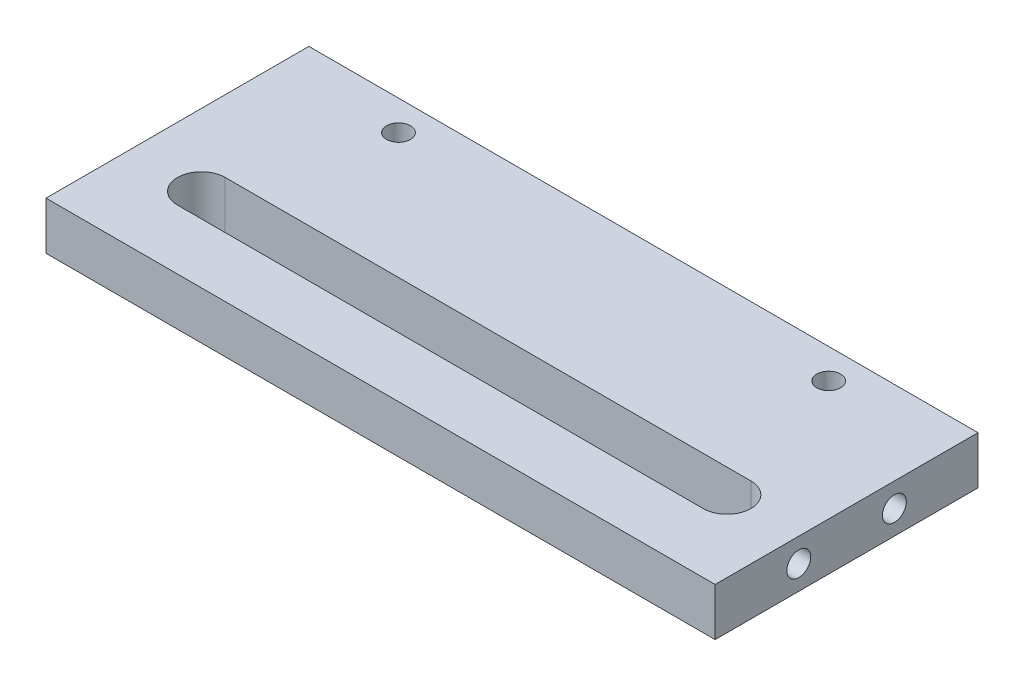
from build123d import *

# Parameters (mm, degrees)
CROQUIS1_W              = 280
CROQUIS1_H              = 110
SALIENTE_EXTRUIR1_DEPTH = 20
CORTAR_EXTRUIR2_DEPTH   = 20
CROQUIS4_R              = 5
CORTAR_EXTRUIR4_DEPTH   = 20
CROQUIS5_R              = 5
CORTAR_EXTRUIR5_DEPTH   = 18
CROQUIS6_R              = 5
CORTAR_EXTRUIR6_DEPTH   = 18


with BuildPart() as part:
    # Croquis1 → Saliente-Extruir1 (new body)
    with BuildSketch(Plane(origin=(0, 0, 0), x_dir=(1, 0, 0), z_dir=(0, 1, 0))):
        with Locations((14.294294294, 1.756756757)):
            Rectangle(CROQUIS1_W, CROQUIS1_H)
    extrude(amount=SALIENTE_EXTRUIR1_DEPTH)

    # Croquis2 → Cortar-Extruir2 (cut)
    with BuildSketch(Plane(origin=(0, 0, 0), x_dir=(1, 0, 0), z_dir=(0, 1, 0))):
        with BuildLine():
            Line((-95.705705706, -8.243243243), (124.294294294, -8.243243243))
            ThreePointArc((124.294294294, -8.243243243), (134.294294294, -18.243243243), (124.294294294, -28.243243243))
            Line((124.294294294, -28.243243243), (-95.705705706, -28.243243243))
            ThreePointArc((-95.705705706, -28.243243243), (-105.705705706, -18.243243243), (-95.705705706, -8.243243243))
        make_face()
    extrude(amount=CORTAR_EXTRUIR2_DEPTH, mode=Mode.SUBTRACT)

    # Croquis4 → Cortar-Extruir4 (cut)
    with BuildSketch(Plane(origin=(0, 0, 0), x_dir=(1, 0, 0), z_dir=(0, 1, 0))):
        with Locations((104.294294294, 44.256756757)):
            Circle(CROQUIS4_R)
        with Locations((-75.705705706, 44.256756757)):
            Circle(CROQUIS4_R)
    extrude(amount=CORTAR_EXTRUIR4_DEPTH, mode=Mode.SUBTRACT)

    # Croquis5 → Cortar-Extruir5 (cut)
    with BuildSketch(Plane.ZY.offset(125.705705706)):
        with Locations((18.243243243, 10)):
            Circle(CROQUIS5_R)
        with Locations((-21.756756757, 10)):
            Circle(CROQUIS5_R)
    extrude(amount=-CORTAR_EXTRUIR5_DEPTH, mode=Mode.SUBTRACT)

    # Croquis6 → Cortar-Extruir6 (cut)
    with BuildSketch(Plane(origin=(154.294294294, 0, 0), x_dir=(0, 0, -1), z_dir=(1, 0, 0))):
        with Locations((21.756756757, 10)):
            Circle(CROQUIS6_R)
        with Locations((-18.243243243, 10)):
            Circle(CROQUIS6_R)
    extrude(amount=-CORTAR_EXTRUIR6_DEPTH, mode=Mode.SUBTRACT)


solid = part.part
